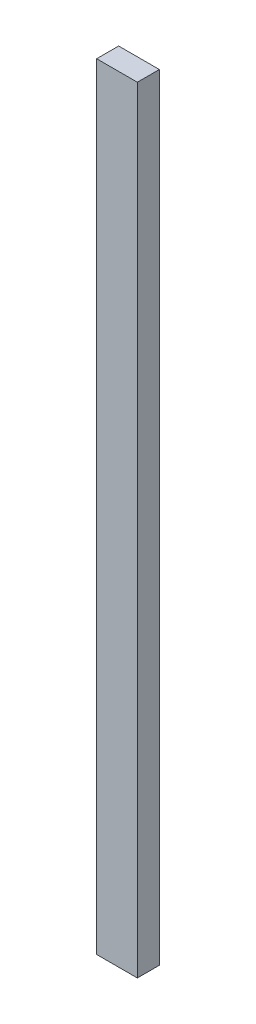
from build123d import *

# Parameters (mm, degrees)
SKETCH1_W           = 104.955242986
SKETCH1_H           = 56.73976334
BOSS_EXTRUDE1_DEPTH = 2000


with BuildPart() as part:
    # Sketch1 → Boss-Extrude1 (new body)
    with BuildSketch(Plane(origin=(0, 0, 0), x_dir=(1, 0, 0), z_dir=(0, 1, 0))):
        with Locations((11.054930416, -11.188122349)):
            Rectangle(SKETCH1_W, SKETCH1_H)
    extrude(amount=BOSS_EXTRUDE1_DEPTH)


solid = part.part
